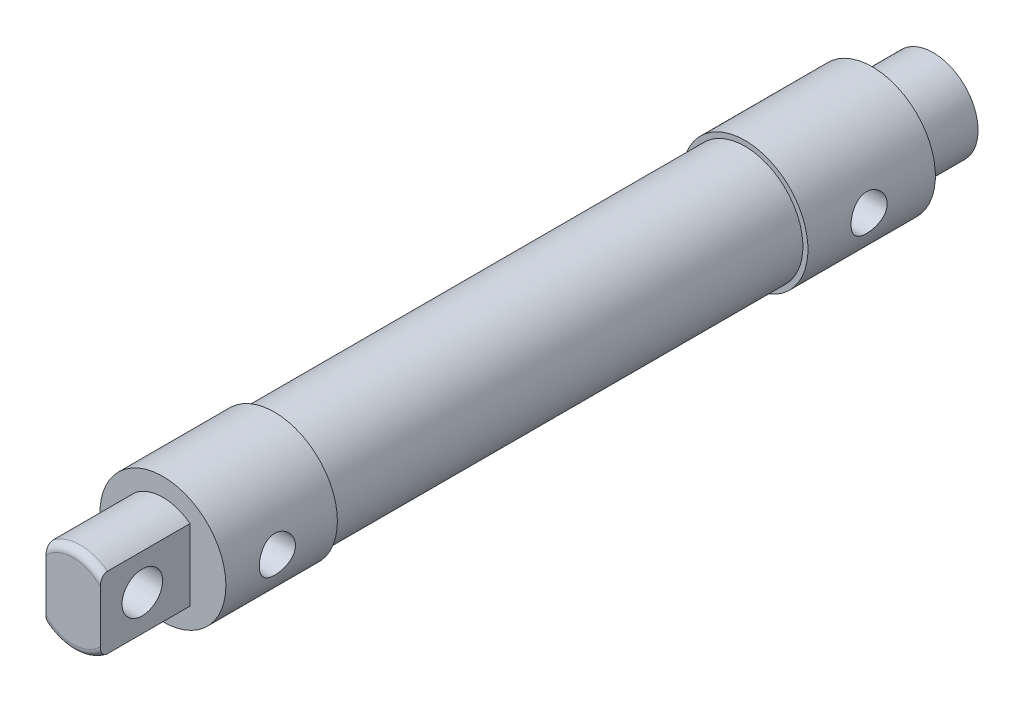
from build123d import *

# Parameters (mm, degrees)
SKETCH1_R           = 10.16
BOSS_EXTRUDE1_DEPTH = 82.55
SKETCH2_R           = 11.049
BOSS_EXTRUDE2_DEPTH = 19.558
BOSS_EXTRUDE3_DEPTH = 15.748
SKETCH4_R           = 3.556
CUT_EXTRUDE1_DEPTH  = 9.525
FILLET1_R           = 1.27
SKETCH5_R           = 11.049
BOSS_EXTRUDE4_DEPTH = 22.352
SKETCH6_R           = 7.874
BOSS_EXTRUDE5_DEPTH = 10.668
SKETCH7_R           = 3.175
CUT_EXTRUDE2_DEPTH  = 124.968
SKETCH8_R           = 3.175
CUT_EXTRUDE3_DEPTH  = 11.049


with BuildPart() as part:
    # Sketch1 → Boss-Extrude1 (new body)
    with BuildSketch(Plane.XY):
        Circle(SKETCH1_R)
    extrude(amount=BOSS_EXTRUDE1_DEPTH)

    # Sketch5 → Boss-Extrude4 (add)
    with BuildSketch(Plane(origin=(0, 0, 0), x_dir=(-1, 0, 0), z_dir=(0, 0, -1))):
        Circle(SKETCH5_R)
    extrude(amount=BOSS_EXTRUDE4_DEPTH)

    # Sketch6 → Boss-Extrude5 (add)
    with BuildSketch(Plane(origin=(0, 0, -22.352), x_dir=(-1, 0, 0), z_dir=(0, 0, -1))):
        Circle(SKETCH6_R)
    extrude(amount=BOSS_EXTRUDE5_DEPTH)


with BuildPart() as body_2:
    # Sketch2 → Boss-Extrude2 (new body)
    with BuildSketch(Plane.XY.offset(82.55)):
        Circle(SKETCH2_R)
    extrude(amount=BOSS_EXTRUDE2_DEPTH)

    # Sketch3 → Boss-Extrude3 (add)
    with BuildSketch(Plane.XY.offset(102.108)):
        with BuildLine():
            Line((4.7625, -6.270444143), (4.7625, 6.270444143))
            ThreePointArc((4.7625, 6.270444143), (0, 7.874), (-4.7625, 6.270444143))
            Line((-4.7625, 6.270444143), (-4.7625, -6.270444143))
            ThreePointArc((-4.7625, -6.270444143), (0, -7.874), (4.7625, -6.270444143))
        make_face()
    extrude(amount=BOSS_EXTRUDE3_DEPTH)

    # Sketch4 → Cut-Extrude1 (cut)
    with BuildSketch(Plane(origin=(4.7625, 0, 0), x_dir=(0, 0, -1), z_dir=(1, 0, 0))):
        with Locations((-110.49, 0)):
            Circle(SKETCH4_R)
    extrude(amount=-CUT_EXTRUDE1_DEPTH, mode=Mode.SUBTRACT)

    # Fillet1
    fillet1_edges = [body_2.edges().sort_by_distance(p)[0] for p in [
        (0, 7.874, 117.856),
        (0, -7.874, 117.856),
    ]]
    fillet(fillet1_edges, radius=FILLET1_R)


with BuildPart() as cut_extrude2_tool:
    # Sketch7 → Cut-Extrude2 (new body)
    with BuildSketch(Plane(origin=(0, 0, -33.02), x_dir=(-1, 0, 0), z_dir=(0, 0, -1))):
        Circle(SKETCH7_R)
    extrude(amount=-CUT_EXTRUDE2_DEPTH)


with BuildPart() as part_1:
    add(part.part)

    # Cut-Extrude2: cut by cut_extrude2_tool
    add(cut_extrude2_tool.part, mode=Mode.SUBTRACT)


with BuildPart() as body_2_1:
    add(body_2.part)

    # Cut-Extrude2: cut by cut_extrude2_tool
    add(cut_extrude2_tool.part, mode=Mode.SUBTRACT)


with BuildPart() as cut_extrude3_tool:
    # Sketch8 → Cut-Extrude3 (new body)
    with BuildSketch(Plane(origin=(0, 0, 0), x_dir=(0, 0, -1), z_dir=(1, 0, 0))):
        with Locations((-93.076077846, 0)):
            Circle(SKETCH8_R)
        with Locations((10.739797543, 0)):
            Circle(SKETCH8_R)
    extrude(amount=CUT_EXTRUDE3_DEPTH)


with BuildPart() as part_2:
    add(part_1.part)

    # Cut-Extrude3: cut by cut_extrude3_tool
    add(cut_extrude3_tool.part, mode=Mode.SUBTRACT)


with BuildPart() as body_2_2:
    add(body_2_1.part)

    # Cut-Extrude3: cut by cut_extrude3_tool
    add(cut_extrude3_tool.part, mode=Mode.SUBTRACT)


solid = Compound([part_2.part, body_2_2.part])
